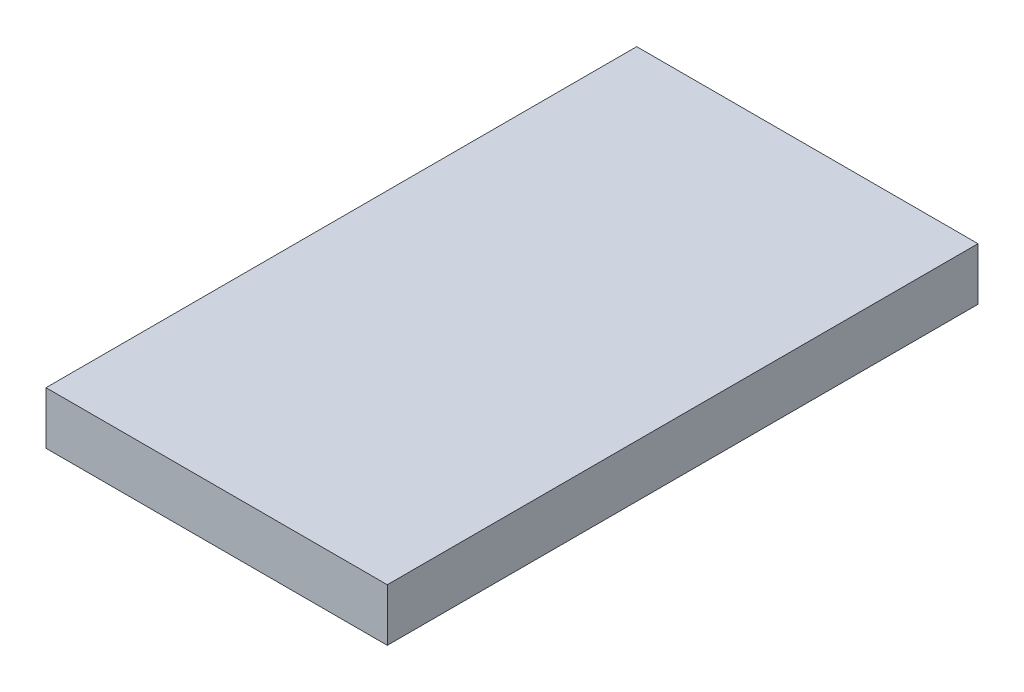
from build123d import *

# Parameters (mm, degrees)
BASES_W    = 10.4
BASES_H    = 18
BASE_DEPTH = 1.6


with BuildPart() as part:
    # BaseS → Base (new body)
    with BuildSketch(Plane(origin=(0, 0, 0), x_dir=(1, 0, 0), z_dir=(0, 1, 0))):
        Rectangle(BASES_W, BASES_H)
    extrude(amount=BASE_DEPTH)


solid = part.part
